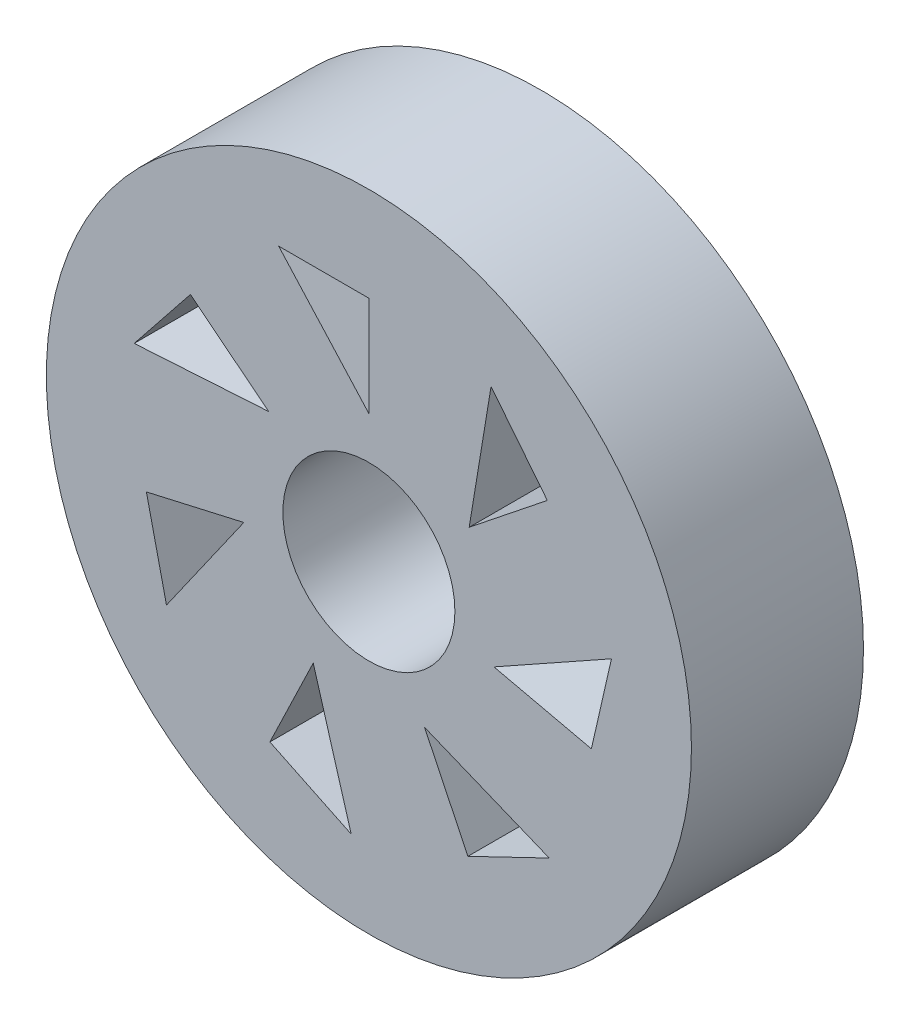
from build123d import *

# Parameters (mm, degrees)
SKETCH1_R           = 19.05
SKETCH1_R_2         = 5.08
BOSS_EXTRUDE2_DEPTH = 10.16
CUT_EXTRUDE2_DEPTH  = 10.16


with BuildPart() as part:
    # Sketch1 → Boss-Extrude2 (new body)
    with BuildSketch(Plane.XY):
        with Locations((-23.004204789, 15.609996107)):
            Circle(SKETCH1_R)
        with Locations((-23.004204789, 15.609996107)):
            Circle(SKETCH1_R_2, mode=Mode.SUBTRACT)
    extrude(amount=BOSS_EXTRUDE2_DEPTH)

    # Sketch3 → Cut-Extrude2 (cut)
    with BuildSketch(Plane.XY.offset(10.16)):
        Polygon((-23.004204789, 23.186689095), (-28.334456331, 29.08814957), (-23.004204789, 29.08814957), align=None)
        Polygon((-12.466560086, 24.013487339), (-17.080507678, 20.333986917), (-15.789917564, 28.180845804), align=None)
        Polygon((-9.863976773, 12.61082481), (-15.617475313, 13.924023307), (-8.677884222, 17.807435817), align=None)
        Polygon((-17.156253168, 3.46659944), (-19.716800906, 8.783631603), (-12.353862471, 5.779308909), align=None)
        Polygon((-28.85215641, 3.46659944), (-26.291608673, 8.783631603), (-24.049765713, 1.153889971), align=None)
        Polygon((-36.144432805, 12.61082481), (-30.390934265, 13.924023307), (-34.958340254, 7.414213804), align=None)
        Polygon((-33.541849492, 24.013487339), (-28.9279019, 20.333986917), (-36.86520697, 19.846128875), align=None)
    extrude(amount=-CUT_EXTRUDE2_DEPTH, mode=Mode.SUBTRACT)


solid = part.part
